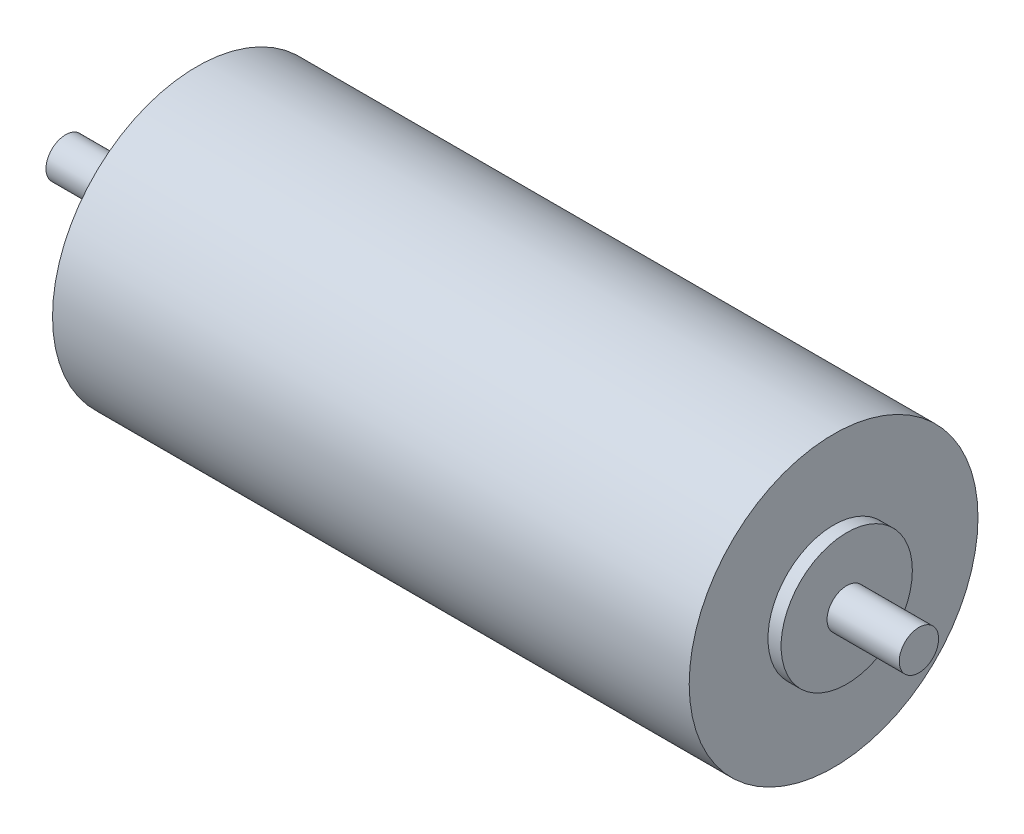
from build123d import *


with BuildPart() as part:
    # Skizze2 → Rotation1 (revolve)
    with BuildSketch(Plane.XY):
        Polygon((-10, 0), (-10, 1.5), (-1, 1.5), (-1, 5), (0, 5), (0, 11), (48.5, 11), (48.5, 5), (49.5, 5), (49.5, 1.5), (55, 1.5), (55, 0), align=None)
    revolve(axis=Axis((56.673133505, 0, 0), (-1, 0, 0)))


solid = part.part
